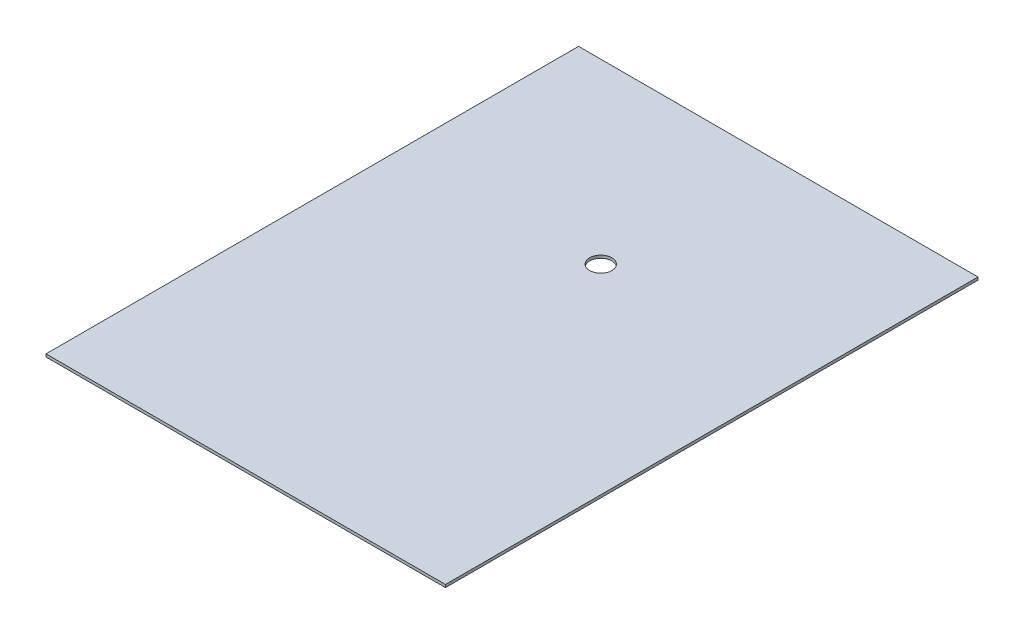
from build123d import *

# Parameters (mm, degrees)
SKETCH1_W           = 457.2
SKETCH1_H           = 609.6
SKETCH1_R           = 12.7
BOSS_EXTRUDE1_DEPTH = 3.175


with BuildPart() as part:
    # Sketch1 → Boss-Extrude1 (new body)
    with BuildSketch(Plane(origin=(0, 0, 0), x_dir=(1, 0, 0), z_dir=(0, 1, 0))):
        Rectangle(SKETCH1_W, SKETCH1_H)
        with Locations((0, 101.6)):
            Circle(SKETCH1_R, mode=Mode.SUBTRACT)
    extrude(amount=BOSS_EXTRUDE1_DEPTH)


solid = part.part
